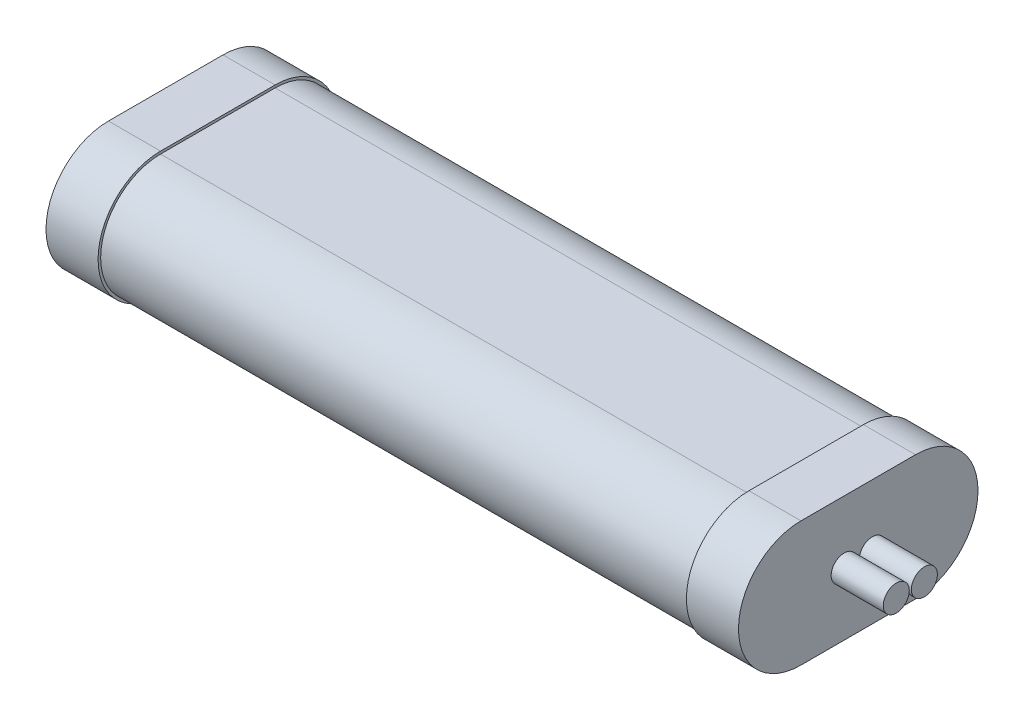
from build123d import *

# Parameters (mm, degrees)
BOSS_EXTRUDE1_DEPTH = 56.5
BOSS_EXTRUDE2_DEPTH = 10
SKETCH3_R           = 2.5
BOSS_EXTRUDE3_DEPTH = 10


with BuildPart() as part:
    # Sketch1 → Boss-Extrude1 (new body, symmetric)
    with BuildSketch(Plane(origin=(0, 0, 0), x_dir=(0, 0, -1), z_dir=(1, 0, 0))):
        with BuildLine():
            Line((-11, 11.5), (11, 11.5))
            ThreePointArc((11, 11.5), (22.5, 0), (11, -11.5))
            Line((11, -11.5), (-11, -11.5))
            ThreePointArc((-11, -11.5), (-22.5, 0), (-11, 11.5))
        make_face()
    extrude(amount=BOSS_EXTRUDE1_DEPTH, both=True)

    # Sketch2 → Boss-Extrude2 (add)
    with BuildSketch(Plane(origin=(56.5, 0, 0), x_dir=(0, 0, -1), z_dir=(1, 0, 0))):
        with BuildLine():
            Line((-11, 12), (11, 12))
            ThreePointArc((11, 12), (23, 0), (11, -12))
            Line((11, -12), (-11, -12))
            ThreePointArc((-11, -12), (-23, 0), (-11, 12))
        make_face()
    boss_extrude2 = extrude(amount=BOSS_EXTRUDE2_DEPTH)

    # Mirror1: Boss-Extrude2 across plane
    add(boss_extrude2.mirror(Plane(origin=(0, 0, 0), x_dir=(0, 0, 1), z_dir=(1, 0, 0))))

    # Sketch3 → Boss-Extrude3 (add)
    with BuildSketch(Plane(origin=(66.5, 0, 0), x_dir=(0, 0, -1), z_dir=(1, 0, 0))):
        with Locations((-2.7, 0)):
            Circle(SKETCH3_R)
        with Locations((2.7, 0)):
            Circle(SKETCH3_R)
    extrude(amount=BOSS_EXTRUDE3_DEPTH)


solid = part.part
